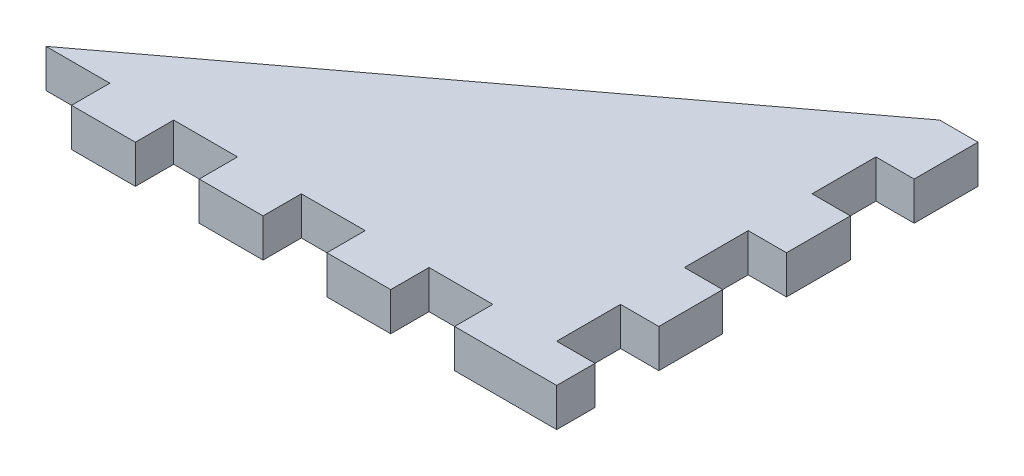
from build123d import *

# Parameters (mm, degrees)
BOSS_EXTRUDE1_DEPTH = 1.5
SKETCH2_W           = 5
SKETCH2_H           = 3
BOSS_EXTRUDE2_DEPTH = 3
SKETCH3_W           = 5
SKETCH3_H           = 3
BOSS_EXTRUDE3_DEPTH = 3
SKETCH4_W           = 3
SKETCH4_H           = 3
BOSS_EXTRUDE4_DEPTH = 3


with BuildPart() as part:
    # Sketch1 → Boss-Extrude1 (new body, symmetric)
    with BuildSketch(Plane(origin=(0, 0, 0), x_dir=(1, 0, 0), z_dir=(0, 1, 0))):
        Polygon((20, 15), (20, -15), (-20, -15), align=None)
    extrude(amount=BOSS_EXTRUDE1_DEPTH, both=True)

    # Sketch2 → Boss-Extrude2 (add)
    with BuildSketch(Plane(origin=(20, 0, 0), x_dir=(0, 0, -1), z_dir=(1, 0, 0))):
        with Locations((12.5, 0)):
            Rectangle(SKETCH2_W, SKETCH2_H)
        with Locations((2.5, 0)):
            Rectangle(SKETCH2_W, SKETCH2_H)
        with Locations((-7.5, 0)):
            Rectangle(SKETCH2_W, SKETCH2_H)
    extrude(amount=BOSS_EXTRUDE2_DEPTH)

    # Sketch3 → Boss-Extrude3 (add)
    with BuildSketch(Plane.XY.offset(15)):
        with Locations((17.5, 0)):
            Rectangle(SKETCH3_W, SKETCH3_H)
        with Locations((7.5, 0)):
            Rectangle(SKETCH3_W, SKETCH3_H)
        with Locations((-2.5, 0)):
            Rectangle(SKETCH3_W, SKETCH3_H)
        with Locations((-12.5, 0)):
            Rectangle(SKETCH3_W, SKETCH3_H)
    extrude(amount=BOSS_EXTRUDE3_DEPTH)

    # Sketch4 → Boss-Extrude4 (add)
    with BuildSketch(Plane(origin=(20, 0, 0), x_dir=(0, 0, -1), z_dir=(1, 0, 0))):
        with Locations((-16.5, 0)):
            Rectangle(SKETCH4_W, SKETCH4_H)
    extrude(amount=BOSS_EXTRUDE4_DEPTH)


solid = part.part
